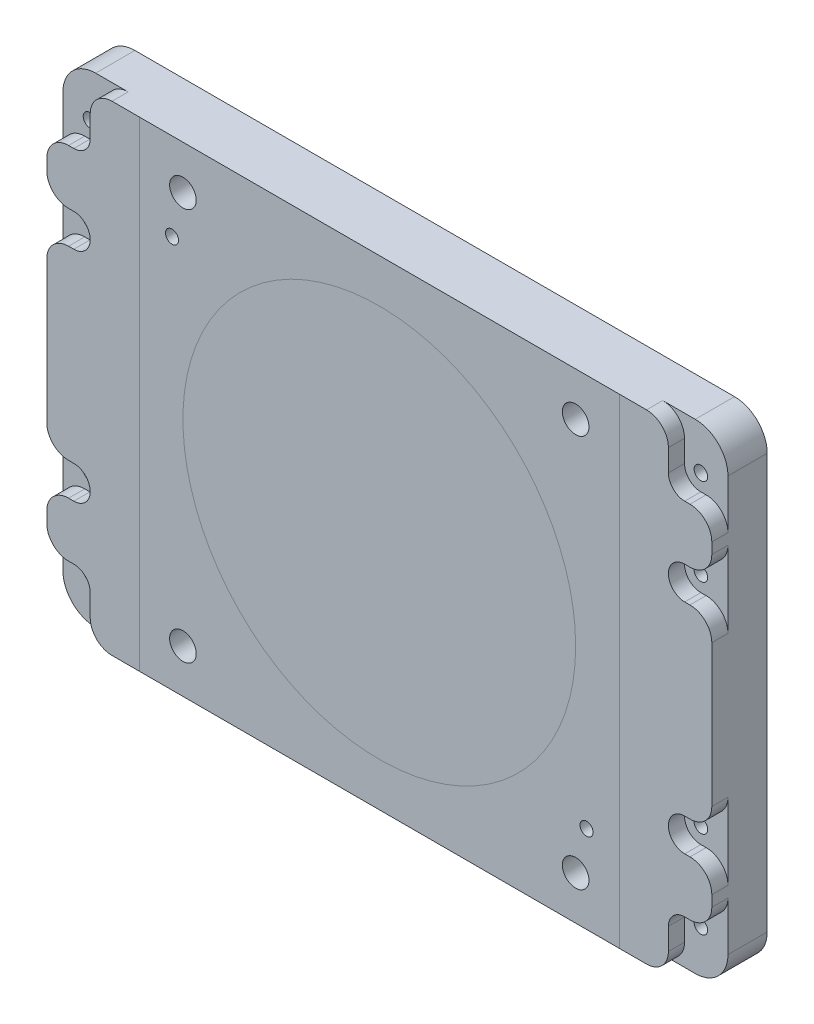
from build123d import *

# Parameters (mm, degrees)
BOSS_EXTRUDE2_DEPTH              = 25.4
CUT_EXTRUDE2_DEPTH               = 26.4
F_10_2_10_2_DIAMETER_HOLE2_D     = 12.2
F_10_2_10_2_DIAMETER_HOLE2_DEPTH = 25.4
F_15_0_15_DIAMETER_HOLE2_D       = 15
F_15_0_15_DIAMETER_HOLE2_DEPTH   = 25.4
SKETCH32_R                       = 300
SKETCH32_W                       = 230
SKETCH32_H                       = 220
CUT_EXTRUDE3_DEPTH               = 26.4
SKETCH33_R                       = 3.1
BOSS_EXTRUDE3_DEPTH              = 25.4
F_6_0_6_DIAMETER_HOLE3_D         = 6
F_6_0_6_DIAMETER_HOLE3_DEPTH     = 10
F_6_0_6_DIAMETER_HOLE3_TIP       = 1.802581857
CUT_EXTRUDE4_DEPTH               = 7.4
FILLET1_R                        = 10


with BuildPart() as part:
    # Sketch18 → Boss-Extrude2 (new body)
    with BuildSketch(Plane(origin=(0, 0, 0), x_dir=(-1, 0, 0), z_dir=(0, 0, -1))):
        with BuildLine():
            Line((20, -40), (-20, -40))
            ThreePointArc((-20, -40), (-41.213203436, -31.213203436), (-50, -10))
            Line((-50, -10), (-50, -5))
            Line((-50, -5), (-55, 0))
            Line((-55, 0), (-50, 5))
            Line((-50, 5), (-50, 100))
            ThreePointArc((-50, 100), (-52.928932188, 107.071067812), (-60, 110))
            Line((-60, 110), (-165, 110))
            ThreePointArc((-165, 110), (-172.071067812, 107.071067812), (-175, 100))
            Line((-175, 100), (-175, 40))
            ThreePointArc((-175, 40), (-172.071067812, 32.928932188), (-165, 30))
            Line((-165, 30), (-155, 30))
            ThreePointArc((-155, 30), (-126.715728753, 18.284271247), (-115, -10))
            Line((-115, -10), (-115, -104.24379092))
            ThreePointArc((-115, -104.24379092), (-114.870742021, -104.951126971), (-114.499675711, -105.567034195))
            Line((-114.499675711, -105.567034195), (-40.597138287, -189.323243274))
            ThreePointArc((-40.597138287, -189.323243274), (-39.920114828, -189.822976488), (-39.097462577, -190))
            Line((-39.097462577, -190), (39.097462577, -190))
            ThreePointArc((39.097462577, -190), (39.920114828, -189.822976488), (40.597138287, -189.323243274))
            Line((40.597138287, -189.323243274), (114.499675711, -105.567034195))
            ThreePointArc((114.499675711, -105.567034195), (114.870742021, -104.951126971), (115, -104.24379092))
            Line((115, -104.24379092), (115, -10))
            ThreePointArc((115, -10), (126.715728753, 18.284271247), (155, 30))
            Line((155, 30), (165, 30))
            ThreePointArc((165, 30), (172.071067812, 32.928932188), (175, 40))
            Line((175, 40), (175, 100))
            ThreePointArc((175, 100), (172.071067812, 107.071067812), (165, 110))
            Line((165, 110), (60, 110))
            ThreePointArc((60, 110), (52.928932188, 107.071067812), (50, 100))
            Line((50, 100), (50, 5))
            Line((50, 5), (55, 0))
            Line((55, 0), (50, -5))
            Line((50, -5), (50, -10))
            ThreePointArc((50, -10), (41.213203436, -31.213203436), (20, -40))
        make_face()
    extrude(amount=-BOSS_EXTRUDE2_DEPTH)

    # Sketch19 → Cut-Extrude2 (cut, through all)
    with BuildSketch(Plane(origin=(0, 0, 0), x_dir=(-1, 0, 0), z_dir=(0, 0, -1))):
        Polygon((-5, -40), (0, -45), (5, -40), align=None)
    extrude(amount=-CUT_EXTRUDE2_DEPTH, mode=Mode.SUBTRACT)

    # Ø10.2 (10.2) Diameter Hole2
    with Locations(Plane(origin=(0, 0, 0), x_dir=(-1, 0, 0), z_dir=(0, 0, -1))):
        with Locations((-90, -90), (90, -90), (-90, 90), (90, 90)):
            Hole(F_10_2_10_2_DIAMETER_HOLE2_D / 2, depth=F_10_2_10_2_DIAMETER_HOLE2_DEPTH)

    # Ø15.0 (15) Diameter Hole2
    with Locations(Plane(origin=(0, 0, 0), x_dir=(-1, 0, 0), z_dir=(0, 0, -1))):
        with Locations((0, -150), (-135, 60), (135, 60)):
            Hole(F_15_0_15_DIAMETER_HOLE2_D / 2, depth=F_15_0_15_DIAMETER_HOLE2_DEPTH)

    # Sketch32 → Cut-Extrude3 (cut, through all)
    with BuildSketch(Plane.XY):
        Circle(SKETCH32_R)
        Rectangle(SKETCH32_W, SKETCH32_H, mode=Mode.SUBTRACT)
    extrude(amount=CUT_EXTRUDE3_DEPTH, mode=Mode.SUBTRACT)

    # Sketch33 → Boss-Extrude3 (add)
    with BuildSketch(Plane.XY):
        with BuildLine():
            Line((137.4, 110), (115, 110))
            Line((115, 110), (115, -104.24379092))
            ThreePointArc((115, -104.24379092), (114.870742021, -104.951126971), (114.499675711, -105.567034195))
            Line((114.499675711, -105.567034195), (110.588235294, -110))
            Line((110.588235294, -110), (137.4, -110))
            ThreePointArc((137.4, -110), (148.006601718, -105.606601718), (152.4, -95))
            Line((152.4, -95), (152.4, 95))
            ThreePointArc((152.4, 95), (148.006601718, 105.606601718), (137.4, 110))
        make_face()
        with Locations((140, -90)):
            Circle(SKETCH33_R, mode=Mode.SUBTRACT)
        with Locations((140, -50)):
            Circle(SKETCH33_R, mode=Mode.SUBTRACT)
        with Locations((140, 50)):
            Circle(SKETCH33_R, mode=Mode.SUBTRACT)
        with Locations((140, 90)):
            Circle(SKETCH33_R, mode=Mode.SUBTRACT)
        with BuildLine():
            ThreePointArc((50, 100), (52.928932188, 107.071067812), (60, 110))
            Line((60, 110), (-60, 110))
            ThreePointArc((-60, 110), (-52.928932188, 107.071067812), (-50, 100))
            Line((-50, 100), (-50, 5))
            Line((-50, 5), (-55, 0))
            Line((-55, 0), (-50, -5))
            Line((-50, -5), (-50, -10))
            ThreePointArc((-50, -10), (-41.213203436, -31.213203436), (-20, -40))
            Line((-20, -40), (-5, -40))
            Line((-5, -40), (0, -45))
            Line((0, -45), (5, -40))
            Line((5, -40), (20, -40))
            ThreePointArc((20, -40), (41.213203436, -31.213203436), (50, -10))
            Line((50, -10), (50, -5))
            Line((50, -5), (55, 0))
            Line((55, 0), (50, 5))
            Line((50, 5), (50, 100))
        make_face()
        with BuildLine():
            Line((-115, -104.24379092), (-115, 110))
            Line((-115, 110), (-137.4, 110))
            ThreePointArc((-137.4, 110), (-148.006601718, 105.606601718), (-152.4, 95))
            Line((-152.4, 95), (-152.4, -95))
            ThreePointArc((-152.4, -95), (-148.006601718, -105.606601718), (-137.4, -110))
            Line((-137.4, -110), (-110.588235294, -110))
            Line((-110.588235294, -110), (-114.499675711, -105.567034195))
            ThreePointArc((-114.499675711, -105.567034195), (-114.870742021, -104.951126971), (-115, -104.24379092))
        make_face()
        with Locations((-140, -90)):
            Circle(SKETCH33_R, mode=Mode.SUBTRACT)
        with Locations((-140, -50)):
            Circle(SKETCH33_R, mode=Mode.SUBTRACT)
        with Locations((-140, 50)):
            Circle(SKETCH33_R, mode=Mode.SUBTRACT)
        with Locations((-140, 90)):
            Circle(SKETCH33_R, mode=Mode.SUBTRACT)
    extrude(amount=BOSS_EXTRUDE3_DEPTH)

    # Ø6.0 (6) Diameter Hole3
    with Locations(Plane.XY.offset(25.4)):
        with Locations((95, -70), (-95, 70)):
            Hole(F_6_0_6_DIAMETER_HOLE3_D / 2, depth=F_6_0_6_DIAMETER_HOLE3_DEPTH)
            with Locations((0, 0, -(F_6_0_6_DIAMETER_HOLE3_DEPTH + F_6_0_6_DIAMETER_HOLE3_TIP / 2))):  # 118° drill point
                Cone(0, F_6_0_6_DIAMETER_HOLE3_D / 2, F_6_0_6_DIAMETER_HOLE3_TIP, mode=Mode.SUBTRACT)

    # Sketch34 → Cut-Extrude4 (cut)
    with BuildSketch(Plane.XY.offset(25.4)):
        with BuildLine():
            Line((140, 82.5), (152.4, 82.5))
            Line((152.4, 82.5), (152.4, 110))
            Line((152.4, 110), (132.5, 110))
            Line((132.5, 110), (132.5, 90))
            ThreePointArc((132.5, 90), (134.696699141, 84.696699141), (140, 82.5))
        make_face()
        with BuildLine():
            Line((140, 57.5), (152.4, 57.5))
            Line((152.4, 57.5), (152.4, 42.5))
            Line((152.4, 42.5), (140, 42.5))
            ThreePointArc((140, 42.5), (132.5, 50), (140, 57.5))
        make_face()
        with BuildLine():
            Line((140, -57.5), (152.4, -57.5))
            Line((152.4, -57.5), (152.4, -42.5))
            Line((152.4, -42.5), (140, -42.5))
            ThreePointArc((140, -42.5), (132.5, -50), (140, -57.5))
        make_face()
        with BuildLine():
            Line((132.5, -90), (132.5, -110))
            Line((132.5, -110), (152.4, -110))
            Line((152.4, -110), (152.4, -82.5))
            Line((152.4, -82.5), (140, -82.5))
            ThreePointArc((140, -82.5), (134.696699141, -84.696699141), (132.5, -90))
        make_face()
        with BuildLine():
            Line((-140, -82.5), (-152.4, -82.5))
            Line((-152.4, -82.5), (-152.4, -110))
            Line((-152.4, -110), (-132.5, -110))
            Line((-132.5, -110), (-132.5, -90))
            ThreePointArc((-132.5, -90), (-134.696699141, -84.696699141), (-140, -82.5))
        make_face()
        with BuildLine():
            Line((-152.4, -42.5), (-140, -42.5))
            ThreePointArc((-140, -42.5), (-132.5, -50), (-140, -57.5))
            Line((-140, -57.5), (-152.4, -57.5))
            Line((-152.4, -57.5), (-152.4, -42.5))
        make_face()
        with BuildLine():
            Line((-140, 57.5), (-152.4, 57.5))
            Line((-152.4, 57.5), (-152.4, 42.5))
            Line((-152.4, 42.5), (-140, 42.5))
            ThreePointArc((-140, 42.5), (-132.5, 50), (-140, 57.5))
        make_face()
        with BuildLine():
            Line((-132.5, 90), (-132.5, 110))
            Line((-132.5, 110), (-152.4, 110))
            Line((-152.4, 110), (-152.4, 82.5))
            Line((-152.4, 82.5), (-140, 82.5))
            ThreePointArc((-140, 82.5), (-134.696699141, 84.696699141), (-132.5, 90))
        make_face()
    extrude(amount=-CUT_EXTRUDE4_DEPTH, mode=Mode.SUBTRACT)

    # Fillet1
    fillet1_edges = [part.edges().sort_by_distance(p)[0] for p in [
        (152.4, 57.5, 21.7),
        (152.4, 42.5, 21.7),
        (152.4, -42.5, 21.7),
        (152.4, -57.5, 21.7),
        (152.4, -82.5, 21.7),
        (132.5, -110, 21.7),
        (-132.5, -110, 21.7),
        (-152.4, -82.5, 21.7),
        (-152.4, -57.5, 21.7),
        (-152.4, -42.5, 21.7),
        (-152.4, 42.5, 21.7),
        (-152.4, 57.5, 21.7),
        (-152.4, 82.5, 21.7),
        (-132.5, 110, 21.7),
        (132.5, 110, 21.7),
        (152.4, 82.5, 21.7),
    ]]
    fillet(fillet1_edges, radius=FILLET1_R)


solid = part.part
